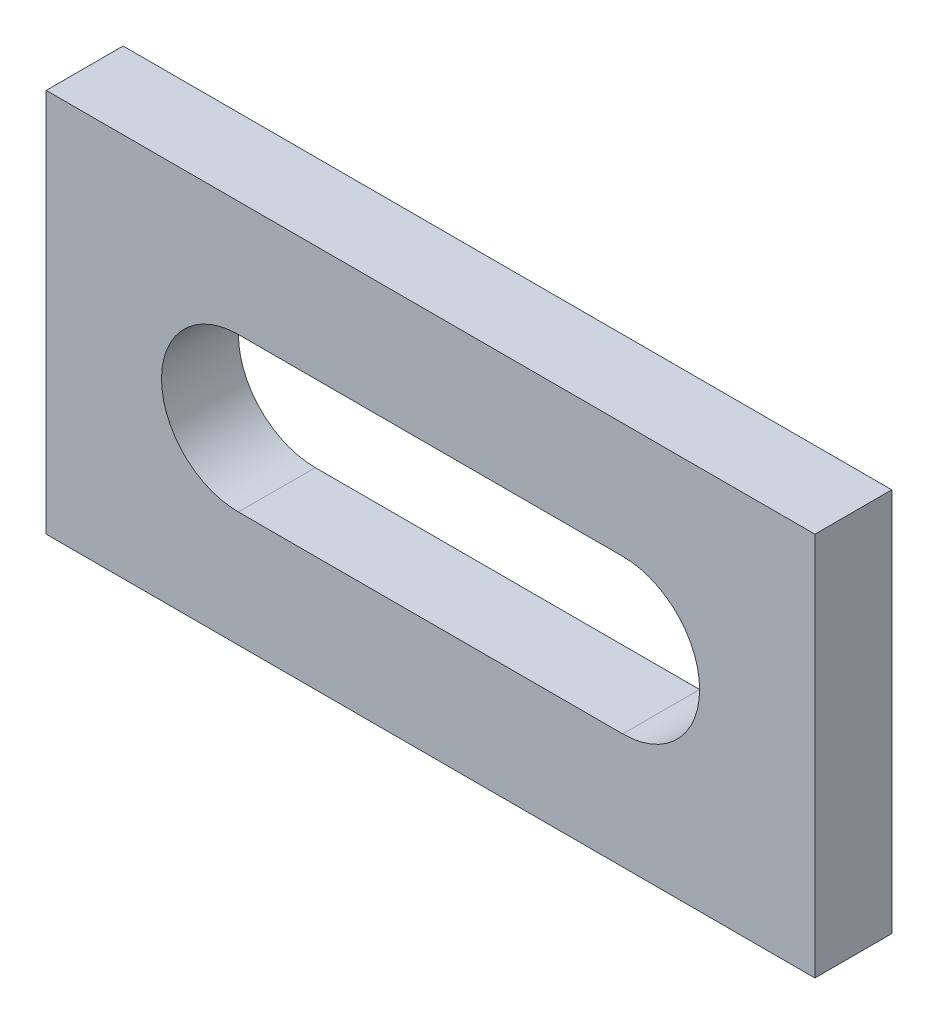
from build123d import *

# Parameters (mm, degrees)
SKETCH2_W       = 100
SKETCH2_H       = 50
BOX_DEPTH       = 5
HOLE_DEPTH      = 6
HOLE_DEPTH_BACK = 6


with BuildPart() as part:
    # Sketch2 → Box (new body, symmetric)
    with BuildSketch(Plane.XY):
        Rectangle(SKETCH2_W, SKETCH2_H)
    extrude(amount=BOX_DEPTH, both=True)

    # Sketch3 → Hole (cut, two sides)
    with BuildSketch(Plane.XY) as hole_sk:
        with BuildLine():
            Line((-25, 10), (25, 10))
            ThreePointArc((25, 10), (35, 0), (25, -10))
            Line((25, -10), (-25, -10))
            ThreePointArc((-25, -10), (-35, 0), (-25, 10))
        make_face()
    extrude(amount=HOLE_DEPTH, mode=Mode.SUBTRACT)
    extrude(hole_sk.sketch, amount=-HOLE_DEPTH_BACK, mode=Mode.SUBTRACT)


solid = part.part
